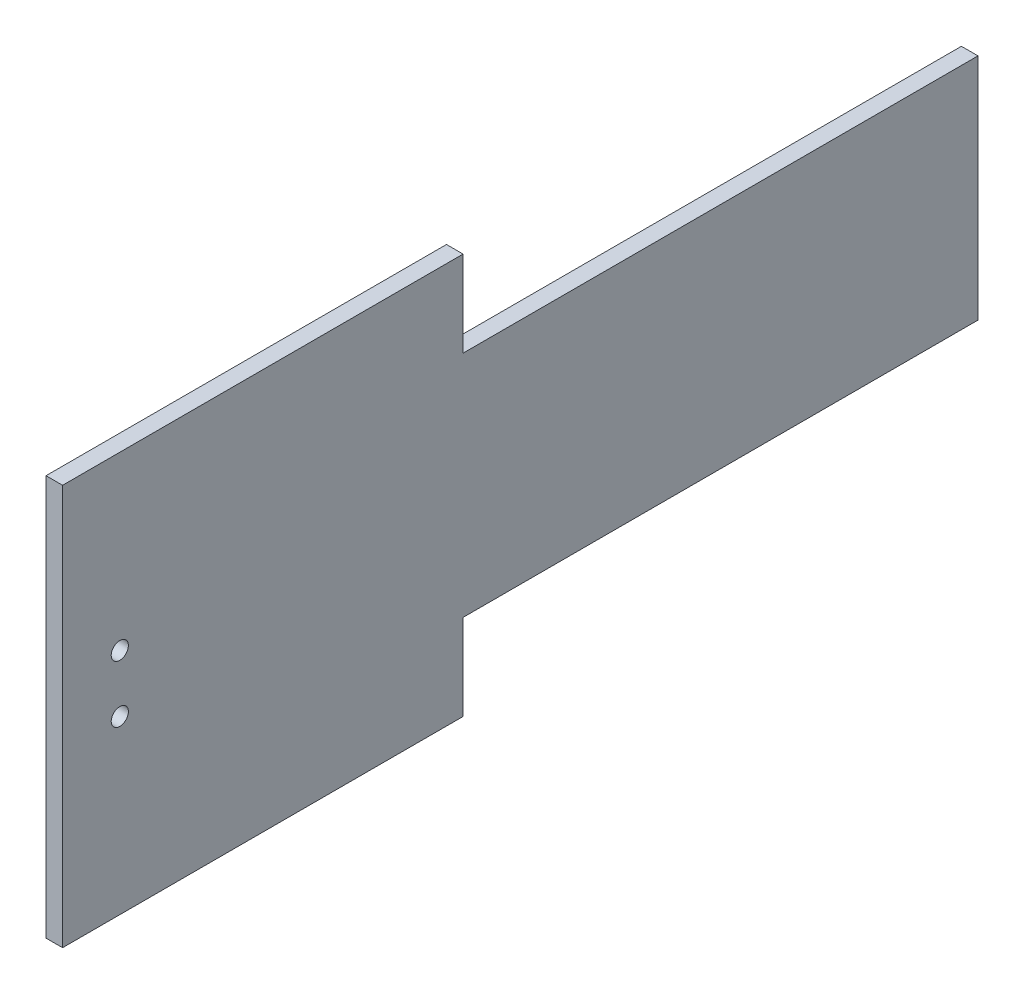
from build123d import *

# Parameters (mm, degrees)
SKETCH1_R           = 1.5
BOSS_EXTRUDE1_DEPTH = 2.9


with BuildPart() as part:
    # Sketch1 → Boss-Extrude1 (new body)
    with BuildSketch(Plane(origin=(0, 0, 0), x_dir=(0, 0, -1), z_dir=(1, 0, 0))):
        Polygon((-35, 35), (35, 35), (35, 20), (125, 20), (125, -20), (35, -20), (35, -35), (-35, -35), align=None)
        with Locations((-25, 5)):
            Circle(SKETCH1_R, mode=Mode.SUBTRACT)
        with Locations((-25, -5)):
            Circle(SKETCH1_R, mode=Mode.SUBTRACT)
    extrude(amount=BOSS_EXTRUDE1_DEPTH)


solid = part.part
